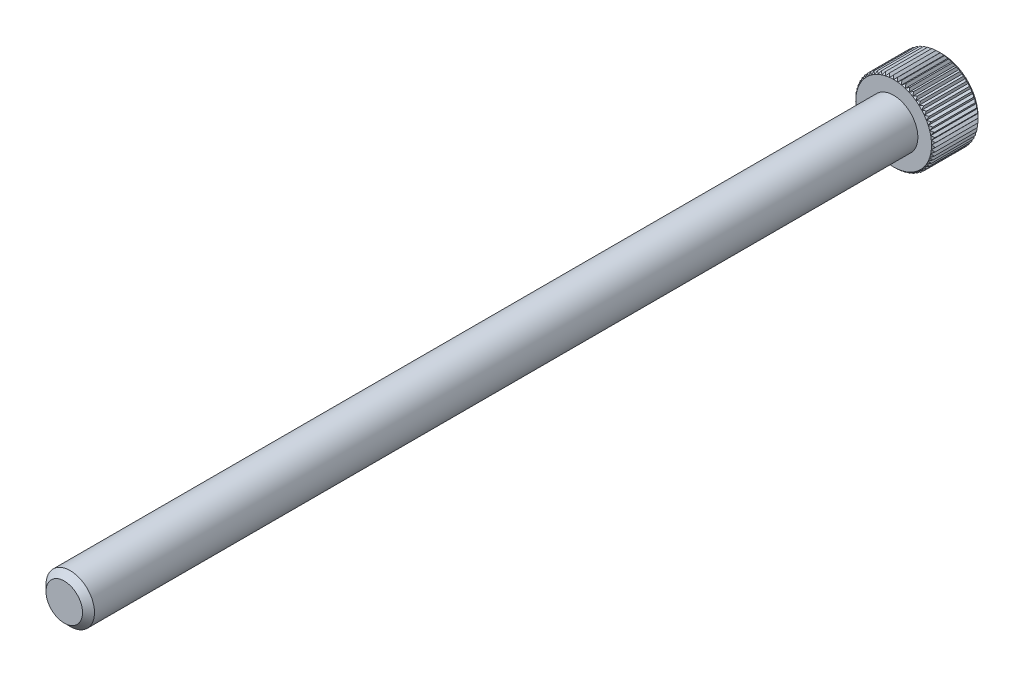
from build123d import *
from build123d.topology import SkipClean

# Parameters (mm, degrees)
SKETCH1_R          = 2.413
EXTRUDE1_DEPTH     = 82.55
CHAMFER3_SIZE      = 0.5953125
SKETCH6_R          = 3.96875
EXTRUDE2_DEPTH     = 4.826
CUT_EXTRUDE1_DEPTH = 2.9765625
CHAMFER1_SIZE      = 0.396875
CHAMFER2_SIZE      = 0.1984375
CUT_EXTRUDE3_DEPTH = 83.740585284
CIRPATTERN1_COUNT  = 60


with BuildPart() as part:
    # Sketch1 → Extrude1 (new body)
    with BuildSketch(Plane.XY):
        Circle(SKETCH1_R)
    extrude(amount=-EXTRUDE1_DEPTH)

    # Chamfer3
    chamfer3_edges = [part.edges().sort_by_distance(p)[0] for p in [
        (-2.413, 0, 0),
    ]]
    chamfer(chamfer3_edges, length=CHAMFER3_SIZE)

    # Sketch6 → Extrude2 (add)
    with BuildSketch(Plane(origin=(0, 0, -82.55), x_dir=(-1, 0, 0), z_dir=(0, 0, -1))):
        Circle(SKETCH6_R)
    extrude(amount=EXTRUDE2_DEPTH)

    # Sketch7 → Cut-Extrude1 (cut)
    with BuildSketch(Plane(origin=(0, 0, -87.376), x_dir=(-1, 0, 0), z_dir=(0, 0, -1))):
        Polygon((0, 2.291358881), (-1.984375, 1.14567944), (-1.984375, -1.14567944), (0, -2.291358881), (1.984375, -1.14567944), (1.984375, 1.14567944), align=None)
    extrude(amount=-CUT_EXTRUDE1_DEPTH, mode=Mode.SUBTRACT)

    # Cut-Extrude2 cone 1 section (through the dimple's axis) → Cut-Extrude2 (revolve, cut)
    with BuildSketch(Plane(origin=(0, 0, -87.376), x_dir=(0, 1, 0), z_dir=(1, 0, 0))):
        Polygon((0, 0), (2.291358881, 0), (0, 2.291358881), align=None)
    revolve(axis=Axis((0, 0, -87.376), (0, 0, 1)), mode=Mode.SUBTRACT)

    # Chamfer1
    chamfer1_edges = [part.edges().sort_by_distance(p)[0] for p in [
        (3.96875, 0, -87.376),
    ]]
    chamfer(chamfer1_edges, length=CHAMFER1_SIZE)

    # Chamfer2
    chamfer2_edges = [part.edges().sort_by_distance(p)[0] for p in [
        (3.96875, 0, -82.55),
    ]]
    chamfer(chamfer2_edges, length=CHAMFER2_SIZE)

    # Sketch10 → Cut-Extrude3 (cut, through all)
    with SkipClean():  # the faces are left unmerged after this step: merging them gives an invalid solid
        with BuildSketch(Plane.XY.offset(-82.55)):
            Polygon((-0.42712382, 4.1671875), (0, 3.7703125), (0.42712382, 4.1671875), align=None)
        cut_extrude3 = extrude(amount=-CUT_EXTRUDE3_DEPTH, mode=Mode.SUBTRACT)

    # CirPattern1: Cut-Extrude3 ×60 about axis
    cirpattern1_axis = Axis((0, 0, -87.376), (0, 0, 1))
    for i in range(1, CIRPATTERN1_COUNT):
        add(cut_extrude3.rotate(cirpattern1_axis, i * 360 / CIRPATTERN1_COUNT), mode=Mode.SUBTRACT)


solid = part.part
